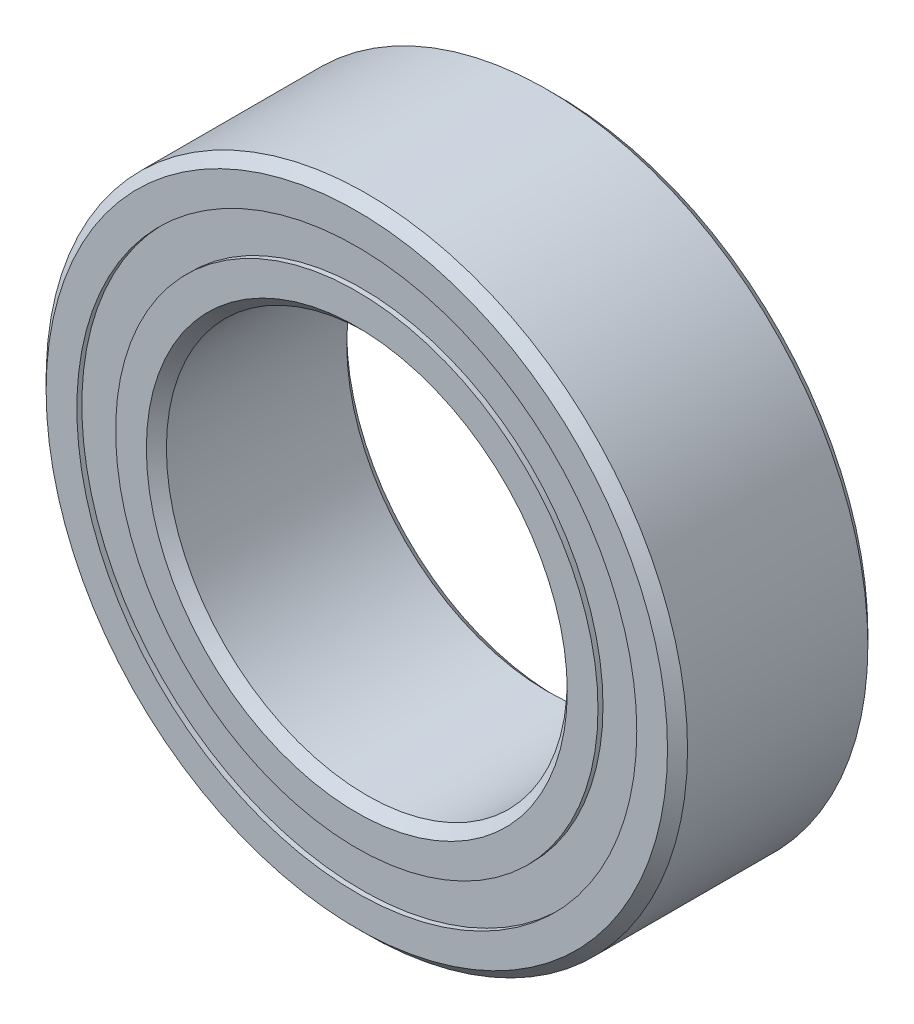
from build123d import *

# Parameters (mm, degrees)
CIRPATTERN1_COUNT = 16
SKETCH5_W         = 0.922957025
SKETCH5_H         = 0.767694066


with BuildPart() as part:
    # Sketch1 → Revolve1 (revolve)
    with BuildSketch(Plane(origin=(0, 0, 0), x_dir=(0, 0, -1), z_dir=(1, 0, 0))):
        with BuildLine():
            Line((1.785366, 6.35), (-1.785366, 6.35))
            Line((-1.785366, 6.35), (-1.98374, 6.151626))
            Line((-1.98374, 6.151626), (-1.98374, 5.543222033))
            Line((-1.98374, 5.543222033), (-0.881662222, 5.543222033))
            ThreePointArc((-0.881662222, 5.543222033), (0, 6.120970975), (0.881662222, 5.543222033))
            Line((0.881662222, 5.543222033), (1.98374, 5.543222033))
            Line((1.98374, 5.543222033), (1.98374, 6.151626))
            Line((1.98374, 6.151626), (1.785366, 6.35))
        make_face()
    revolve(axis=Axis((0, 0, 1.98374), (0, 0, -1)))


with BuildPart() as body_2:
    # Sketch3 → Revolve3 (revolve)
    with BuildSketch(Plane(origin=(0, 0, 0), x_dir=(0, 0, -1), z_dir=(1, 0, 0))):
        with BuildLine():
            Line((-0.881662222, 4.775527967), (-1.98374, 4.775527967))
            Line((-1.98374, 4.775527967), (-1.98374, 4.167124))
            Line((-1.98374, 4.167124), (-1.785366, 3.96875))
            Line((-1.785366, 3.96875), (1.785366, 3.96875))
            Line((1.785366, 3.96875), (1.98374, 4.167124))
            Line((1.98374, 4.167124), (1.98374, 4.775527967))
            Line((1.98374, 4.775527967), (0.881662222, 4.775527967))
            ThreePointArc((0.881662222, 4.775527967), (0, 4.197779025), (-0.881662222, 4.775527967))
        make_face()
    revolve(axis=Axis((0, 0, 1.98374), (0, 0, -1)))


with BuildPart() as body_3:
    # Sketch4 → Revolve4 (revolve)
    with BuildSketch(Plane(origin=(0, 0, 0), x_dir=(0, 0, -1), z_dir=(1, 0, 0))):
        with BuildLine():
            Line((-0.961595975, 5.159375), (0.961595975, 5.159375))
            ThreePointArc((0.961595975, 5.159375), (0, 6.120970975), (-0.961595975, 5.159375))
        make_face()
    revolve(axis=Axis((0, 5.159375, 0.961595975), (0, 0, -1)))


with BuildPart() as cirpattern1_1:
    # CirPattern1: pattern copy
    add(body_3.part.rotate(Axis((0, 0, 0), (0, 0, 1)), 1 * 360 / CIRPATTERN1_COUNT))


with BuildPart() as cirpattern1_2:
    # CirPattern1: pattern copy
    add(body_3.part.rotate(Axis((0, 0, 0), (0, 0, 1)), 2 * 360 / CIRPATTERN1_COUNT))


with BuildPart() as cirpattern1_3:
    # CirPattern1: pattern copy
    add(body_3.part.rotate(Axis((0, 0, 0), (0, 0, 1)), 3 * 360 / CIRPATTERN1_COUNT))


with BuildPart() as cirpattern1_4:
    # CirPattern1: pattern copy
    add(body_3.part.rotate(Axis((0, 0, 0), (0, 0, 1)), 4 * 360 / CIRPATTERN1_COUNT))


with BuildPart() as cirpattern1_5:
    # CirPattern1: pattern copy
    add(body_3.part.rotate(Axis((0, 0, 0), (0, 0, 1)), 5 * 360 / CIRPATTERN1_COUNT))


with BuildPart() as cirpattern1_6:
    # CirPattern1: pattern copy
    add(body_3.part.rotate(Axis((0, 0, 0), (0, 0, 1)), 6 * 360 / CIRPATTERN1_COUNT))


with BuildPart() as cirpattern1_7:
    # CirPattern1: pattern copy
    add(body_3.part.rotate(Axis((0, 0, 0), (0, 0, 1)), 7 * 360 / CIRPATTERN1_COUNT))


with BuildPart() as cirpattern1_8:
    # CirPattern1: pattern copy
    add(body_3.part.rotate(Axis((0, 0, 0), (0, 0, 1)), 8 * 360 / CIRPATTERN1_COUNT))


with BuildPart() as cirpattern1_9:
    # CirPattern1: pattern copy
    add(body_3.part.rotate(Axis((0, 0, 0), (0, 0, 1)), 9 * 360 / CIRPATTERN1_COUNT))


with BuildPart() as cirpattern1_10:
    # CirPattern1: pattern copy
    add(body_3.part.rotate(Axis((0, 0, 0), (0, 0, 1)), 10 * 360 / CIRPATTERN1_COUNT))


with BuildPart() as cirpattern1_11:
    # CirPattern1: pattern copy
    add(body_3.part.rotate(Axis((0, 0, 0), (0, 0, 1)), 11 * 360 / CIRPATTERN1_COUNT))


with BuildPart() as cirpattern1_12:
    # CirPattern1: pattern copy
    add(body_3.part.rotate(Axis((0, 0, 0), (0, 0, 1)), 12 * 360 / CIRPATTERN1_COUNT))


with BuildPart() as cirpattern1_13:
    # CirPattern1: pattern copy
    add(body_3.part.rotate(Axis((0, 0, 0), (0, 0, 1)), 13 * 360 / CIRPATTERN1_COUNT))


with BuildPart() as cirpattern1_14:
    # CirPattern1: pattern copy
    add(body_3.part.rotate(Axis((0, 0, 0), (0, 0, 1)), 14 * 360 / CIRPATTERN1_COUNT))


with BuildPart() as cirpattern1_15:
    # CirPattern1: pattern copy
    add(body_3.part.rotate(Axis((0, 0, 0), (0, 0, 1)), 15 * 360 / CIRPATTERN1_COUNT))


with BuildPart() as body_19:
    # Sketch5 → Revolve5 (revolve)
    with BuildSketch(Plane(origin=(0, 0, 0), x_dir=(0, 0, -1), z_dir=(1, 0, 0))):
        with Locations((-1.423074488, 5.159375)):
            Rectangle(SKETCH5_W, SKETCH5_H)
        with Locations((1.423074488, 5.159375)):
            Rectangle(SKETCH5_W, SKETCH5_H)
    revolve(axis=Axis((0, 0, 1.98374), (0, 0, -1)))


solid = Compound([part.part, body_2.part, body_3.part, cirpattern1_1.part, cirpattern1_2.part, cirpattern1_3.part, cirpattern1_4.part, cirpattern1_5.part, cirpattern1_6.part, cirpattern1_7.part, cirpattern1_8.part, cirpattern1_9.part, cirpattern1_10.part, cirpattern1_11.part, cirpattern1_12.part, cirpattern1_13.part, cirpattern1_14.part, cirpattern1_15.part, body_19.part])
